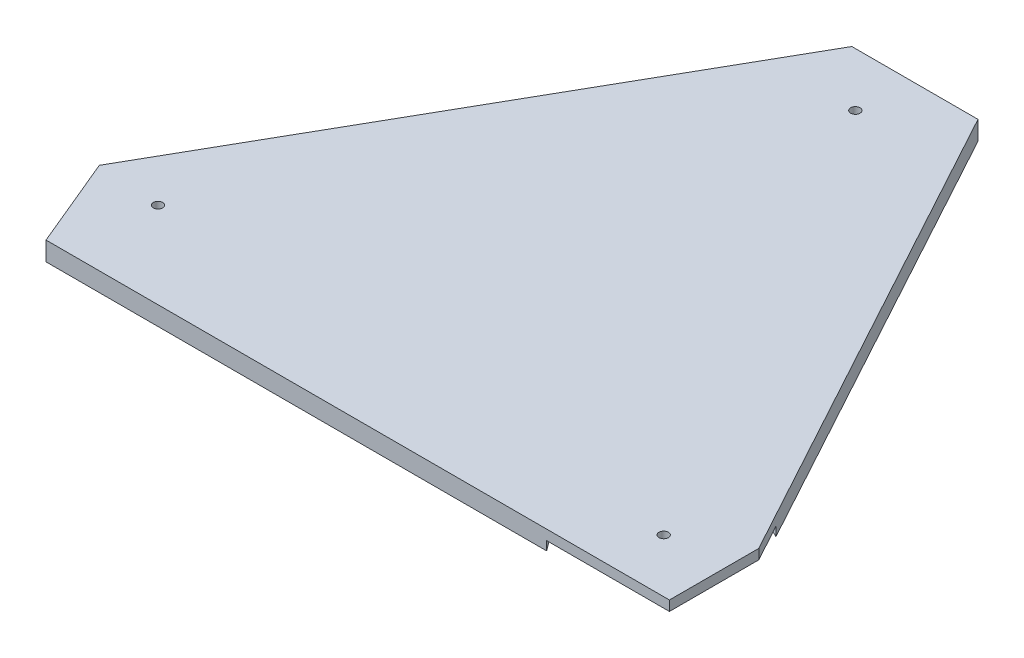
from build123d import *

# Parameters (mm, degrees)
BOSS_EXTRUDE1_DEPTH = 15.875
SKETCH2_R           = 3.96875
CUT_EXTRUDE1_DEPTH  = 16.875
SKETCH3_R           = 63.5
SKETCH3_R_2         = 69.85
CUT_EXTRUDE2_DEPTH  = 7.493


with BuildPart() as part:
    # Sketch1 → Boss-Extrude1 (new body)
    with BuildSketch(Plane(origin=(0, 0, 0), x_dir=(1, 0, 0), z_dir=(0, 1, 0))):
        Polygon((0, 0), (-523.875, 0), (-555.849378124, 76.79442277), (-326.138209959, 479.425), (-220.118609959, 479.425), (0, 75.0824), align=None)
    extrude(amount=BOSS_EXTRUDE1_DEPTH)

    # Sketch2 → Cut-Extrude1 (cut, through all)
    with BuildSketch(Plane(origin=(0, 15.875, 0), x_dir=(1, 0, 0), z_dir=(0, 1, 0))):
        with Locations((-278.106809959, 434.34)):
            Circle(SKETCH2_R)
        with Locations((-502.204578124, 72.4408)):
            Circle(SKETCH2_R)
        with Locations((-49.7332, 44.9326)):
            Circle(SKETCH2_R)
    extrude(amount=-CUT_EXTRUDE1_DEPTH, mode=Mode.SUBTRACT)

    # Sketch3 → Cut-Extrude2 (cut)
    with BuildSketch(Plane.XZ):
        with Locations((-502.204578124, -72.4408)):
            Circle(SKETCH3_R)
        with Locations((-49.7332, -44.9326)):
            Circle(SKETCH3_R_2)
        with Locations((-278.106809959, -434.34)):
            Circle(SKETCH3_R)
    extrude(amount=-CUT_EXTRUDE2_DEPTH, mode=Mode.SUBTRACT)


solid = part.part
